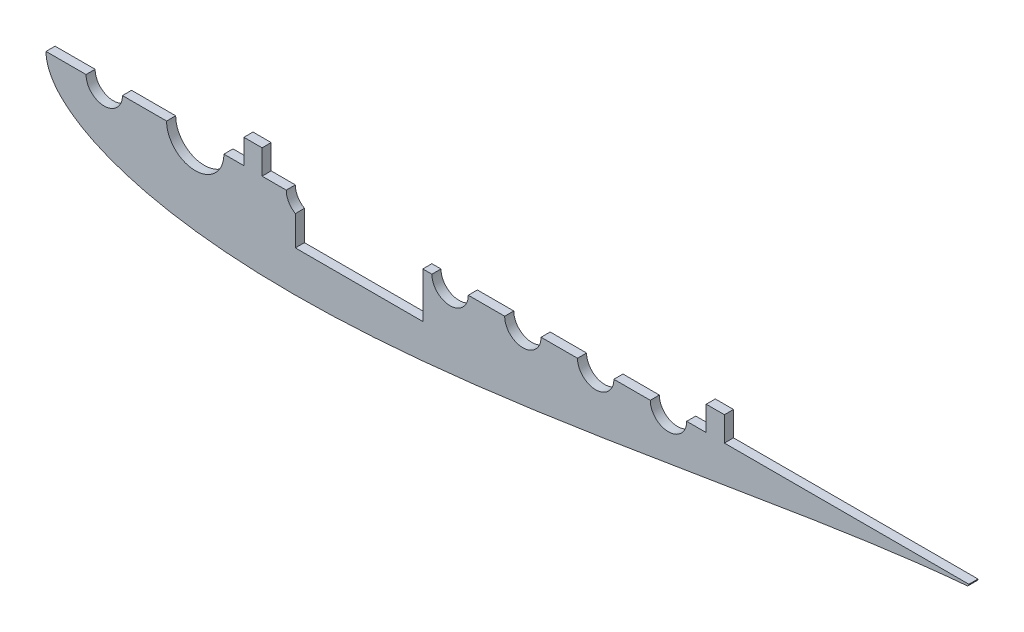
from build123d import *

# Parameters (mm, degrees)
BOSS_EXTRUDE1_DEPTH = 6.35


with BuildPart() as part:
    # Sketch2 → Boss-Extrude1 (new body)
    with BuildSketch(Plane.XY):
        with BuildLine():
            Line((138.080965279, 0), (124.14, 0))
            ThreePointArc((124.14, 0), (104.14, -20), (84.14, 0))
            Line((84.14, 0), (53.34, 0))
            ThreePointArc((53.34, 0), (40.64, -12.7), (27.94, 0))
            Line((27.94, 0), (0, 0))
            add(Edge.make_bspline(
                [(0, 0), (0, -1.007496172), (0.154611582, -3.513796615), (1.106333228, -7.923389435), (3.463136343, -13.420354421), (7.689616489, -19.513207632), (13.932423524, -25.726412106), (22.129107375, -31.731455339), (32.141645239, -37.332204029), (43.82045433, -42.41500246), (57.023709725, -46.912543066), (71.619696083, -50.784752003), (87.485018636, -54.008935199), (104.502313427, -56.574303932), (122.558104573, -58.481758104), (141.542033828, -59.739895824), (161.345829027, -60.366961324), (181.863132616, -60.387506142), (202.989192599, -59.8341217), (224.620860897, -58.745176641), (246.65655865, -57.164603829), (268.996310773, -55.141201012), (291.541767704, -52.727712704), (314.196207315, -49.979843895), (336.86454415, -46.955447457), (359.453314895, -43.713502532), (381.870662856, -40.313266856), (404.02631566, -36.813220545), (425.831595832, -33.270324121), (447.199424328, -29.739007432), (468.044367735, -26.27043606), (488.282710288, -22.911672601), (507.832591566, -19.705111663), (526.614143658, -16.687720753), (544.549749946, -13.890665375), (561.564270734, -11.338919625), (577.585454095, -9.050636147), (592.543922516, -7.037634907), (606.374988512, -5.304428983), (619.014124193, -3.849253664), (630.413817462, -2.663385493), (638.093728429, -1.953546407), (641.993392355, -1.625070631), (642.510849283, -1.582039112)],
                knots=[0.5, 0.5, 0.5, 0.5, 0.502166769, 0.505390167, 0.509655974, 0.514947682, 0.521244711, 0.528520886, 0.536744945, 0.54588136, 0.555890751, 0.566730119, 0.57835299, 0.590709588, 0.603747039, 0.617409572, 0.631638768, 0.646373793, 0.661551658, 0.677107483, 0.692974771, 0.709085713, 0.725371443, 0.741762353, 0.758188398, 0.774579367, 0.790865214, 0.806976332, 0.822843867, 0.838400002, 0.853578262, 0.868313774, 0.882543568, 0.896206835, 0.909245173, 0.92160287, 0.933227116, 0.944068236, 0.954079898, 0.963219316, 0.971447445, 0.978729112, 0.979842958, 0.979842958, 0.979842958, 0.979842958], degree=3))
            ThreePointArc((642.510849283, -1.582039112), (643.547407924, -1.075012082), (643.966787522, 0))
            Line((643.966787522, 0), (473.360965279, 0))
            Line((473.360965279, 0), (473.360965279, 17.145))
            Line((473.360965279, 17.145), (460.660965279, 17.145))
            Line((460.660965279, 17.145), (460.660965279, 0))
            Line((460.660965279, 0), (447.04, 0))
            ThreePointArc((447.04, 0), (434.34, -12.7), (421.64, 0))
            Line((421.64, 0), (396.24, 0))
            ThreePointArc((396.24, 0), (383.54, -12.7), (370.84, 0))
            Line((370.84, 0), (345.44, 0))
            ThreePointArc((345.44, 0), (332.74, -12.7), (320.04, 0))
            Line((320.04, 0), (294.64, 0))
            ThreePointArc((294.64, 0), (281.94, -12.7), (269.24, 0))
            Line((269.24, 0), (262.89, 0))
            Line((262.89, 0), (262.89, -31.75))
            Line((262.89, -31.75), (173.99, -31.75))
            Line((173.99, -31.75), (173.99, -10.998522628))
            ThreePointArc((173.99, -10.998522628), (169.341477372, -6.35), (167.64, 0))
            Line((167.64, 0), (150.780965279, 0))
            Line((150.780965279, 0), (150.780965279, 17.145))
            Line((150.780965279, 17.145), (138.080965279, 17.145))
            Line((138.080965279, 17.145), (138.080965279, 0))
        make_face()
    extrude(amount=BOSS_EXTRUDE1_DEPTH)


solid = part.part
